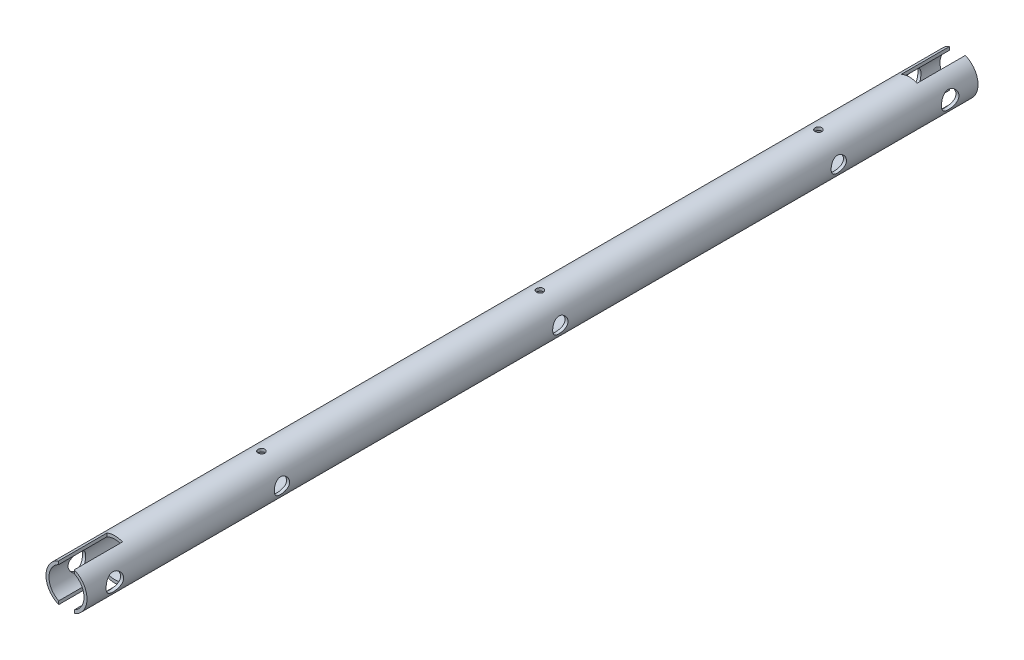
from build123d import *

# Parameters (mm, degrees)
SKETCH1_R                = 9.36
SKETCH1_R_2              = 7.99
EXTRUDE1_DEPTH           = 406.4
SKETCH2_R                = 4
CUT_EXTRUDE1_DEPTH       = 10.36
CUT_EXTRUDE1_DEPTH_BACK  = 10.36
SKETCH4_R                = 4
CUT_EXTRUDE4_DEPTH       = 10.3600001
CUT_EXTRUDE4_DEPTH_BACK  = 10.3600001
SKETCH5_W                = 7.14
SKETCH5_H                = 22
CUT_EXTRUDE5_DEPTH       = 10.3600001
CUT_EXTRUDE5_DEPTH_BACK  = 10.3600001
SKETCH6_W                = 7.1
SKETCH6_H                = 22
CUT_EXTRUDE6_DEPTH       = 10.3600001
CUT_EXTRUDE6_DEPTH_BACK  = 10.3600001
SKETCH7_R                = 3.5
CUT_EXTRUDE7_DEPTH       = 10.3600001
SKETCH8_R                = 3.5
CUT_EXTRUDE9_DEPTH       = 10.3600001
SKETCH9_R                = 3.5
CUT_EXTRUDE10_DEPTH      = 10.3600001
SKETCH10_R               = 1.55
CUT_EXTRUDE11_DEPTH      = 10.3600001
CUT_EXTRUDE11_DEPTH_BACK = 10.3600001
SKETCH11_R               = 1.55
CUT_EXTRUDE12_DEPTH      = 10.360000126
CUT_EXTRUDE12_DEPTH_BACK = 10.360000126
SKETCH12_R               = 1.55
CUT_EXTRUDE13_DEPTH      = 10.360000126
CUT_EXTRUDE13_DEPTH_BACK = 10.360000126


with BuildPart() as part:
    # Sketch1 → Extrude1 (new body)
    with BuildSketch(Plane.XY):
        Circle(SKETCH1_R)
        Circle(SKETCH1_R_2, mode=Mode.SUBTRACT)
    extrude(amount=EXTRUDE1_DEPTH)

    # Sketch2 → Cut-Extrude1 (cut, two sides)
    with BuildSketch(Plane(origin=(0, 0, 0), x_dir=(0, 0, -1), z_dir=(1, 0, 0))) as cut_extrude1_sk:
        with Locations((-12.7, 0)):
            Circle(SKETCH2_R)
    extrude(amount=CUT_EXTRUDE1_DEPTH, mode=Mode.SUBTRACT)
    extrude(cut_extrude1_sk.sketch, amount=-CUT_EXTRUDE1_DEPTH_BACK, mode=Mode.SUBTRACT)

    # Sketch4 → Cut-Extrude4 (cut, two sides)
    with BuildSketch(Plane(origin=(0, 0, 0), x_dir=(0, 0, -1), z_dir=(1, 0, 0))) as cut_extrude4_sk:
        with Locations((-393.7, 0)):
            Circle(SKETCH4_R)
    extrude(amount=CUT_EXTRUDE4_DEPTH, mode=Mode.SUBTRACT)
    extrude(cut_extrude4_sk.sketch, amount=-CUT_EXTRUDE4_DEPTH_BACK, mode=Mode.SUBTRACT)

    # Sketch5 → Cut-Extrude5 (cut, two sides)
    with BuildSketch(Plane(origin=(0, 0, 0), x_dir=(1, 0, 0), z_dir=(0, 1, 0))) as cut_extrude5_sk:
        with Locations((0, -11)):
            Rectangle(SKETCH5_W, SKETCH5_H)
    extrude(amount=CUT_EXTRUDE5_DEPTH, mode=Mode.SUBTRACT)
    extrude(cut_extrude5_sk.sketch, amount=-CUT_EXTRUDE5_DEPTH_BACK, mode=Mode.SUBTRACT)

    # Sketch6 → Cut-Extrude6 (cut, two sides)
    with BuildSketch(Plane(origin=(0, 0, 0), x_dir=(1, 0, 0), z_dir=(0, 1, 0))) as cut_extrude6_sk:
        with Locations((0, -395.4)):
            Rectangle(SKETCH6_W, SKETCH6_H)
    extrude(amount=CUT_EXTRUDE6_DEPTH, mode=Mode.SUBTRACT)
    extrude(cut_extrude6_sk.sketch, amount=-CUT_EXTRUDE6_DEPTH_BACK, mode=Mode.SUBTRACT)

    # Sketch7 → Cut-Extrude7 (cut, through all)
    with BuildSketch(Plane(origin=(0, 0, 0), x_dir=(0, 0, -1), z_dir=(1, 0, 0))):
        with Locations((-63.5, 0)):
            Circle(SKETCH7_R)
    extrude(amount=CUT_EXTRUDE7_DEPTH, mode=Mode.SUBTRACT)

    # Sketch8 → Cut-Extrude9 (cut, through all)
    with BuildSketch(Plane(origin=(0, 0, 0), x_dir=(0, 0, -1), z_dir=(1, 0, 0))):
        with Locations((-190.5, 0)):
            Circle(SKETCH8_R)
    extrude(amount=CUT_EXTRUDE9_DEPTH, mode=Mode.SUBTRACT)

    # Sketch9 → Cut-Extrude10 (cut, through all)
    with BuildSketch(Plane(origin=(0, 0, 0), x_dir=(0, 0, -1), z_dir=(1, 0, 0))):
        with Locations((-317.5, 0)):
            Circle(SKETCH9_R)
    extrude(amount=CUT_EXTRUDE10_DEPTH, mode=Mode.SUBTRACT)

    # Sketch10 → Cut-Extrude11 (cut, two sides)
    with BuildSketch(Plane(origin=(0, 0, 0), x_dir=(1, 0, 0), z_dir=(0, 1, 0))) as cut_extrude11_sk:
        with Locations((0, -63.5)):
            Circle(SKETCH10_R)
    extrude(amount=CUT_EXTRUDE11_DEPTH, mode=Mode.SUBTRACT)
    extrude(cut_extrude11_sk.sketch, amount=-CUT_EXTRUDE11_DEPTH_BACK, mode=Mode.SUBTRACT)

    # Sketch11 → Cut-Extrude12 (cut, two sides)
    with BuildSketch(Plane(origin=(0, 0, 0), x_dir=(1, 0, 0), z_dir=(0, 1, 0))) as cut_extrude12_sk:
        with Locations((0, -190.5)):
            Circle(SKETCH11_R)
    extrude(amount=CUT_EXTRUDE12_DEPTH, mode=Mode.SUBTRACT)
    extrude(cut_extrude12_sk.sketch, amount=-CUT_EXTRUDE12_DEPTH_BACK, mode=Mode.SUBTRACT)

    # Sketch12 → Cut-Extrude13 (cut, two sides)
    with BuildSketch(Plane(origin=(0, 0, 0), x_dir=(1, 0, 0), z_dir=(0, 1, 0))) as cut_extrude13_sk:
        with Locations((0, -317.5)):
            Circle(SKETCH12_R)
    extrude(amount=CUT_EXTRUDE13_DEPTH, mode=Mode.SUBTRACT)
    extrude(cut_extrude13_sk.sketch, amount=-CUT_EXTRUDE13_DEPTH_BACK, mode=Mode.SUBTRACT)


solid = part.part
